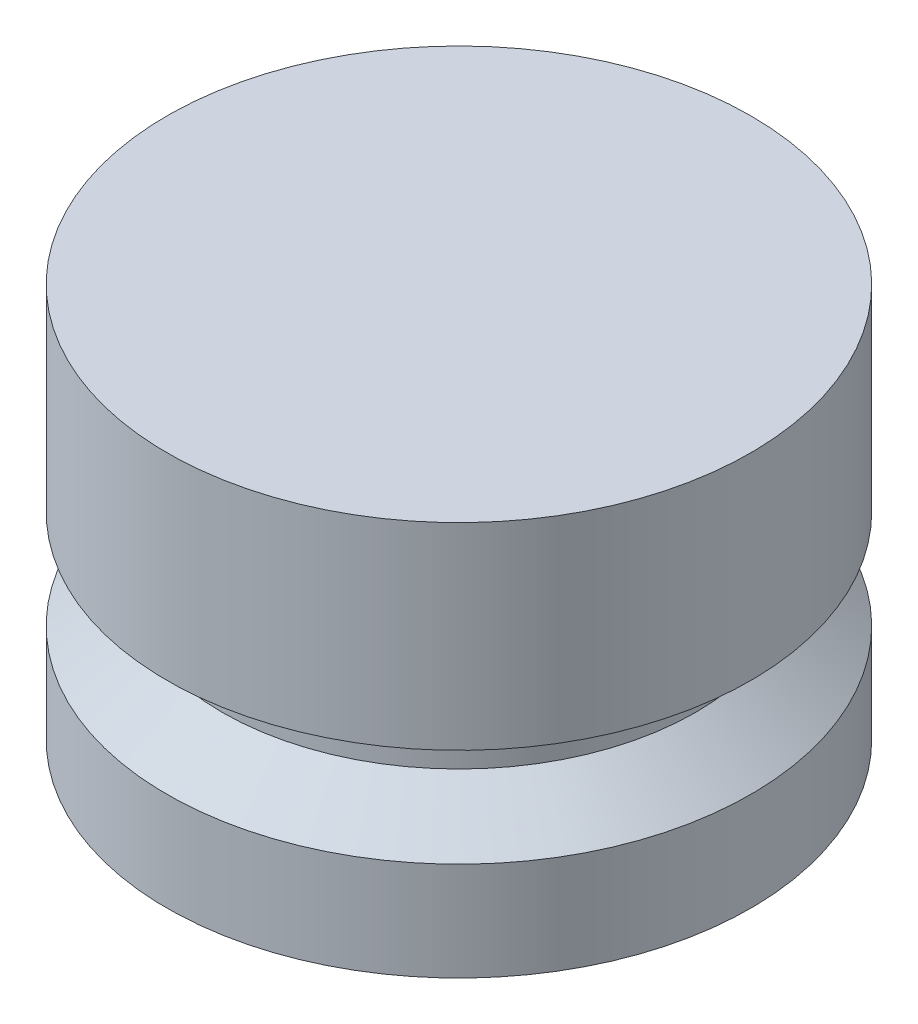
from build123d import *


with BuildPart() as part:
    # Sketch1 → Revolve1 (revolve)
    with BuildSketch(Plane.XY):
        Polygon((0, 0), (-9.398, 0), (-9.398, 3.175), (-7.62, 4.572), (-7.62, 6.35), (-9.398, 6.35), (-9.398, 12.7), (0, 12.7), align=None)
    revolve(axis=Axis((0, 0, 0), (0, 1, 0)))


solid = part.part
